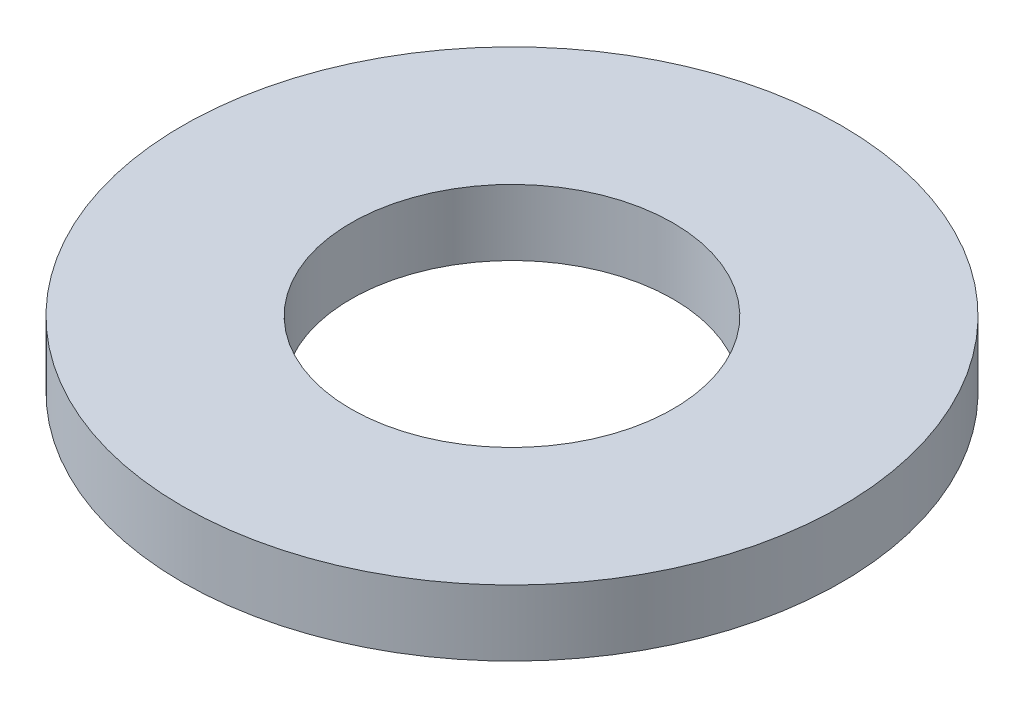
from build123d import *

# Parameters (mm, degrees)
SKETCH1_R           = 4.5
SKETCH1_R_2         = 2.2
BOSS_EXTRUDE1_DEPTH = 0.9


with BuildPart() as part:
    # Sketch1 → Boss-Extrude1 (new body)
    with BuildSketch(Plane(origin=(0, 0, 0), x_dir=(1, 0, 0), z_dir=(0, 1, 0))):
        Circle(SKETCH1_R)
        Circle(SKETCH1_R_2, mode=Mode.SUBTRACT)
    extrude(amount=BOSS_EXTRUDE1_DEPTH)


solid = part.part
